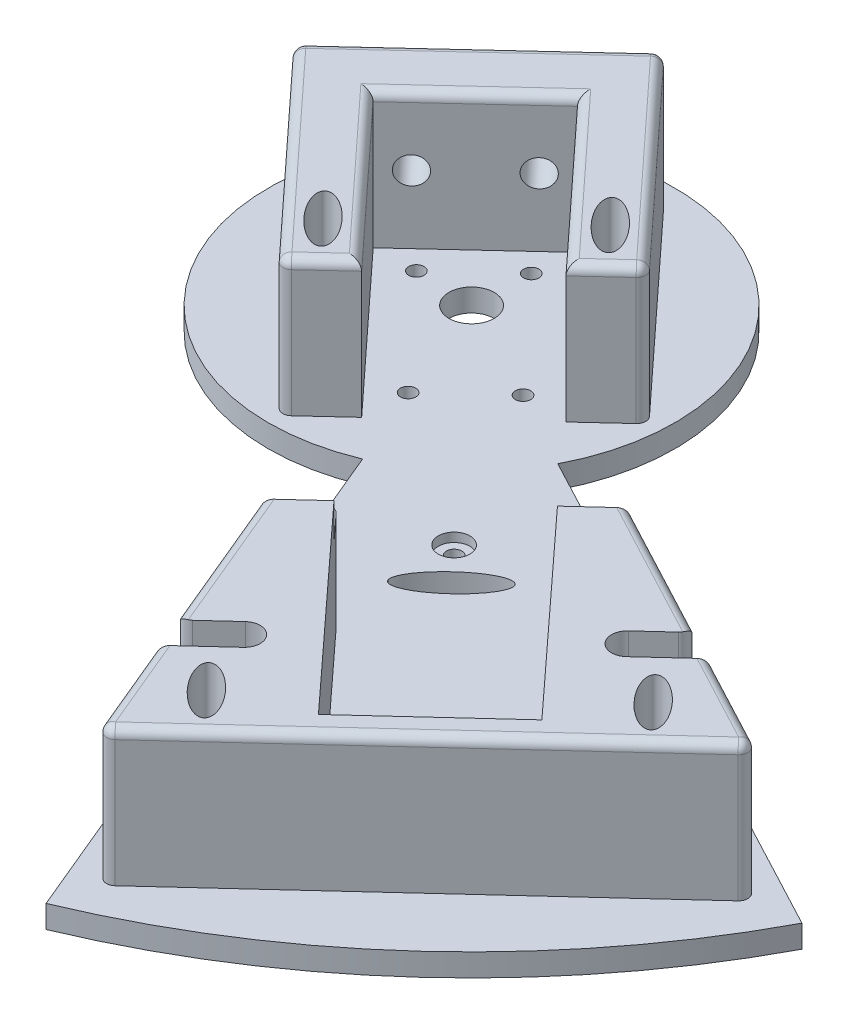
from build123d import *

# Parameters (mm, degrees)
EXTRUDE_1_DEPTH          = 5
SKETCH_1_5_R             = 5
SKETCH_1_5_R_2           = 1.7
CUT_EXTRUDE_2_DEPTH      = 5
EXTRUDE_2_DEPTH          = 30
EXTRUDE_3_DEPTH          = 30
SKETCH_4_R               = 1.7
CUT_EXTRUDE_3_DEPTH      = 30
CUT_EXTRUDE_3_DEPTH_BACK = 30
SKETCH_5_RX              = 7.5
SKETCH_5_RY              = 3
CUT_EXTRUDE_4_DEPTH      = 36
SKETCH_7_R               = 3
CUT_EXTRUDE_5_DEPTH      = 9
SKETCH_8_R               = 1.6
CUT_EXTRUDE_6_DEPTH      = 5
SKETCH_10_R              = 1.5
CUT_EXTRUDE_7_DEPTH      = 5
SKETCH_12_R              = 3
CUT_EXTRUDE_9_DEPTH      = 2
SKETCH_13_R              = 3.5
CUT_EXTRUDE_10_DEPTH     = 2
CUT_EXTRUDE_11_DEPTH     = 30
SKETCH_15_RX             = 10
SKETCH_15_RY             = 3
CUT_EXTRUDE_12_DEPTH     = 10
CUT_EXTRUDE_13_DEPTH     = 30
CUT_EXTRUDE_14_DEPTH     = 8
SKETCH_18_R              = 1.5
CUT_EXTRUDE_15_DEPTH     = 8
FILLET_1_R               = 2


with BuildPart() as part:
    # Sketch 1 → Extrude 1 (new body)
    with BuildSketch(Plane(origin=(0, 0, 0), x_dir=(1, 0, 0), z_dir=(0, 1, 0))):
        with BuildLine():
            Line((67.540595068, -161.712184197), (17.384562367, -41.506348807))
            ThreePointArc((17.384562367, -41.506348807), (-30.453957867, 33.129389524), (39.899218903, -20.80990944))
            Line((39.899218903, -20.80990944), (154.963074519, -81.847468108))
            ThreePointArc((154.963074519, -81.847468108), (118.201370398, -129.387010693), (67.540595068, -161.712184197))
        make_face()
    extrude(amount=EXTRUDE_1_DEPTH)

    # Sketch 1_5 → Cut-Extrude 2 (cut)
    with BuildSketch(Plane(origin=(0, 0, 0), x_dir=(1, 0, 0), z_dir=(0, 1, 0))):
        Circle(SKETCH_1_5_R)
        with Locations((-12.718168021, 0.498198949)):
            Circle(SKETCH_1_5_R_2)
        with Locations((0.498198949, 12.718168021)):
            Circle(SKETCH_1_5_R_2)
        with Locations((9.685108612, -23.731807162)):
            Circle(SKETCH_1_5_R_2)
        with Locations((22.901475581, -11.51183809)):
            Circle(SKETCH_1_5_R_2)
    extrude(amount=CUT_EXTRUDE_2_DEPTH, mode=Mode.SUBTRACT)

    # Sketch 2 → Extrude 2 (add)
    with BuildSketch(Plane(origin=(0, 5, 0), x_dir=(1, 0, 0), z_dir=(0, 1, 0))):
        Polygon((2.136468866, 40.40665523), (8.349325281, 33.687211848), (42.338718823, -3.073625718), (35.730354479, -9.183777478), (32.793384042, -11.899326161), (1.56457419, 21.875833872), (-21.931189311, 0.15144441), (9.297620541, -33.623715623), (6.360650103, -36.339264306), (-0.244095394, -42.446070048), (-34.188453929, -5.733939577), (-40.446345352, 1.0342109), align=None)
    extrude(amount=EXTRUDE_2_DEPTH)

    # Sketch 3 → Extrude 3 (add)
    with BuildSketch(Plane(origin=(0, 5, 0), x_dir=(1, 0, 0), z_dir=(0, 1, 0))):
        Polygon((39.640129458, -80.617349847), (77.002361645, -46.272381189), (145.720646242, -82.725151742), (69.683904227, -152.621391033), align=None)
    extrude(amount=EXTRUDE_3_DEPTH)

    # Sketch 4 → Cut-Extrude 3 (cut, two sides)
    with BuildSketch(Plane(origin=(0, 5, 0), x_dir=(1, 0, 0), z_dir=(0, 1, 0))) as cut_extrude_3_sk:
        with Locations((43.989050253, -47.853562645)):
            Circle(SKETCH_4_R)
        with Locations((67.922104681, -118.218389837)):
            Circle(SKETCH_4_R)
        with Locations((112.094624046, -77.613112681)):
            Circle(SKETCH_4_R)
    extrude(amount=CUT_EXTRUDE_3_DEPTH, mode=Mode.SUBTRACT)
    extrude(cut_extrude_3_sk.sketch, amount=-CUT_EXTRUDE_3_DEPTH_BACK, mode=Mode.SUBTRACT)

    # Sketch 5 → Cut-Extrude 4 (cut, through all)
    with BuildSketch(Plane(origin=(0, 35, 0), x_dir=(1, 0, 0), z_dir=(0, 1, 0))):
        with Locations(Location((74.41780144, -133.105180027), (0, 0, 132.321365352))):
            Ellipse(SKETCH_5_RX, SKETCH_5_RY)
        with Locations(Location((126.174407045, -85.975000987), (0, 0, 132.321365352))):
            Ellipse(SKETCH_5_RX, SKETCH_5_RY)
        with Locations(Location((-3.088812762, -29.798173528), (0, 0, -47.243256279))):
            Ellipse(SKETCH_5_RX, SKETCH_5_RY)
        with Locations(Location((29.952104662, 0.751749153), (0, 0, -47.243256279))):
            Ellipse(SKETCH_5_RX, SKETCH_5_RY)
    extrude(amount=-CUT_EXTRUDE_4_DEPTH, mode=Mode.SUBTRACT)

    # Sketch 7 → Cut-Extrude 5 (cut)
    with BuildSketch(Plane(origin=(-10.18330756, 0, -11.013639141), x_dir=(0.734242609, 0, -0.678887171), z_dir=(0.678887171, 0, 0.734242609))):
        with Locations((-10, 20)):
            Circle(SKETCH_7_R)
        with Locations((10, 20)):
            Circle(SKETCH_7_R)
    extrude(amount=-CUT_EXTRUDE_5_DEPTH, mode=Mode.SUBTRACT)

    # Sketch 8 → Cut-Extrude 6 (cut)
    with BuildSketch(Plane(origin=(-19.156747666, 0, -20.718760056), x_dir=(-0.734242609, 0, 0.678887171), z_dir=(-0.678887171, 0, -0.734242609))):
        with Locations((-10, 20)):
            Circle(SKETCH_8_R)
        with Locations((10, 20)):
            Circle(SKETCH_8_R)
    extrude(amount=-CUT_EXTRUDE_6_DEPTH, mode=Mode.SUBTRACT)

    # Sketch 10 → Cut-Extrude 7 (cut)
    with BuildSketch(Plane(origin=(0, 5, 0), x_dir=(1, 0, 0), z_dir=(0, 1, 0))):
        with Locations((-17.650139673, 33.977138764)):
            Circle(SKETCH_10_R)
        with Locations((-32.374312795, 20.442046379)):
            Circle(SKETCH_10_R)
    extrude(amount=-CUT_EXTRUDE_7_DEPTH, mode=Mode.SUBTRACT)

    # Sketch 12 → Cut-Extrude 9 (cut)
    with BuildSketch(Plane.XZ):
        with Locations((-12.718168021, -0.498198949)):
            Circle(SKETCH_12_R)
        with Locations((9.685108612, 23.731807162)):
            Circle(SKETCH_12_R)
        with Locations((22.901475581, 11.51183809)):
            Circle(SKETCH_12_R)
        with Locations((0.498198949, -12.718168021)):
            Circle(SKETCH_12_R)
    extrude(amount=-CUT_EXTRUDE_9_DEPTH, mode=Mode.SUBTRACT)

    # Sketch 13 → Cut-Extrude 10 (cut)
    with BuildSketch(Plane(origin=(0, 5, 0), x_dir=(1, 0, 0), z_dir=(0, 1, 0))):
        with Locations((43.989050253, -47.853562645)):
            Circle(SKETCH_13_R)
    extrude(amount=-CUT_EXTRUDE_10_DEPTH, mode=Mode.SUBTRACT)

    # Sketch 14 → Cut-Extrude 11 (cut)
    with BuildSketch(Plane(origin=(0, 35, 0), x_dir=(1, 0, 0), z_dir=(0, 1, 0))):
        with BuildLine():
            Line((70.290745848, -120.795120134), (60.254000097, -130.02132794))
            Line((60.254000097, -130.02132794), (57.38653435, -123.149051625))
            Line((57.38653435, -123.149051625), (65.553463513, -115.641659541))
            ThreePointArc((65.553463513, -115.641659541), (70.498834977, -115.84974867), (70.290745848, -120.795120134))
        make_face()
        with BuildLine():
            Line((109.725982878, -75.036382385), (117.593216533, -67.804483285))
            Line((117.593216533, -67.804483285), (124.151890628, -71.283642337))
            Line((124.151890628, -71.283642337), (114.463265213, -80.189842977))
            ThreePointArc((114.463265213, -80.189842977), (109.51789375, -79.981753848), (109.725982878, -75.036382385))
        make_face()
    extrude(amount=-CUT_EXTRUDE_11_DEPTH, mode=Mode.SUBTRACT)

    # Sketch 15 → Cut-Extrude 12 (cut)
    with BuildSketch(Plane(origin=(0, 5, 0), x_dir=(1, 0, 0), z_dir=(0, 1, 0))):
        with Locations(Location((50.923445006, -55.397155695), (0, 0, -137.409444867))):
            Ellipse(SKETCH_15_RX, SKETCH_15_RY)
    extrude(amount=-CUT_EXTRUDE_12_DEPTH, mode=Mode.SUBTRACT)

    # Sketch 16 → Cut-Extrude 13 (cut)
    with BuildSketch(Plane(origin=(0, 35, 0), x_dir=(1, 0, 0), z_dir=(0, 1, 0))):
        Polygon((45.43759407, -75.288071356), (71.204897033, -51.601659681), (111.81017419, -95.774179046), (86.042871227, -119.460590721), align=None)
    extrude(amount=-CUT_EXTRUDE_13_DEPTH, mode=Mode.SUBTRACT)

    # Sketch 17 → Cut-Extrude 14 (cut)
    with BuildSketch(Plane(origin=(0, 35, 0), x_dir=(1, 0, 0), z_dir=(0, 1, 0))):
        Polygon((45.43759407, -75.288071356), (39.640129458, -80.617349847), (43.736509097, -90.43488744), (52.205140263, -82.650157916), align=None)
        Polygon((71.204897033, -51.601659681), (77.002361645, -46.272381189), (86.441074392, -51.179016718), (77.972443226, -58.963746242), align=None)
        Polygon((86.042871227, -119.460590721), (111.81017419, -95.774179046), (117.224211144, -101.663848295), (91.456908181, -125.350259969), align=None)
    extrude(amount=-CUT_EXTRUDE_14_DEPTH, mode=Mode.SUBTRACT)

    # Sketch 18 → Cut-Extrude 15 (cut)
    with BuildSketch(Plane(origin=(0, 27, 0), x_dir=(1, 0, 0), z_dir=(0, 1, 0))):
        with Locations((45.922634861, -81.633753882)):
            Circle(SKETCH_18_R)
        with Locations((77.487402436, -52.618063716)):
            Circle(SKETCH_18_R)
        with Locations((101.633541185, -110.562219508)):
            Circle(SKETCH_18_R)
    extrude(amount=-CUT_EXTRUDE_15_DEPTH, mode=Mode.SUBTRACT)

    # Fillet 1
    fillet_1_edges = [part.edges().sort_by_distance(p)[0] for p in [
        (101.9825563, 35, 59.523545846),
        (64.968952162, 35, 141.321359487),
        (60.254000097, 20, 130.02132794),
        (57.38653435, 20, 123.149051625),
        (117.593216533, 20, 67.804483285),
        (71.204897033, 16, 51.601659681),
        (45.43759407, 16, 75.288071356),
        (50.561521723, 35, 106.791969532),
        (39.640129458, 16, 80.617349847),
        (77.002361645, 16, 46.272381189),
        (-40.446345352, 20, -1.0342109),
        (-0.244095394, 20, 42.446070048),
        (42.338718823, 20, 3.073625718),
        (2.136468866, 20, -40.40665523),
        (-20.345220373, 35, 20.705929574),
        (4.526762573, 35, 38.034892836),
        (-6.316784385, 35, 16.736135606),
        (-10.18330756, 35, -11.013639141),
        (17.178979116, 35, -4.988253856),
        (37.566051433, 35, 7.48647594),
        (22.237593844, 35, -18.666514756),
        (-19.154938243, 35, -20.720433065),
        (69.683904227, 20, 152.621391033),
        (145.720646242, 20, 82.725151742),
        (107.702275234, 35, 117.673271388),
        (134.936268435, 35, 77.00439704),
    ]]
    fillet(fillet_1_edges, radius=FILLET_1_R)


solid = part.part
